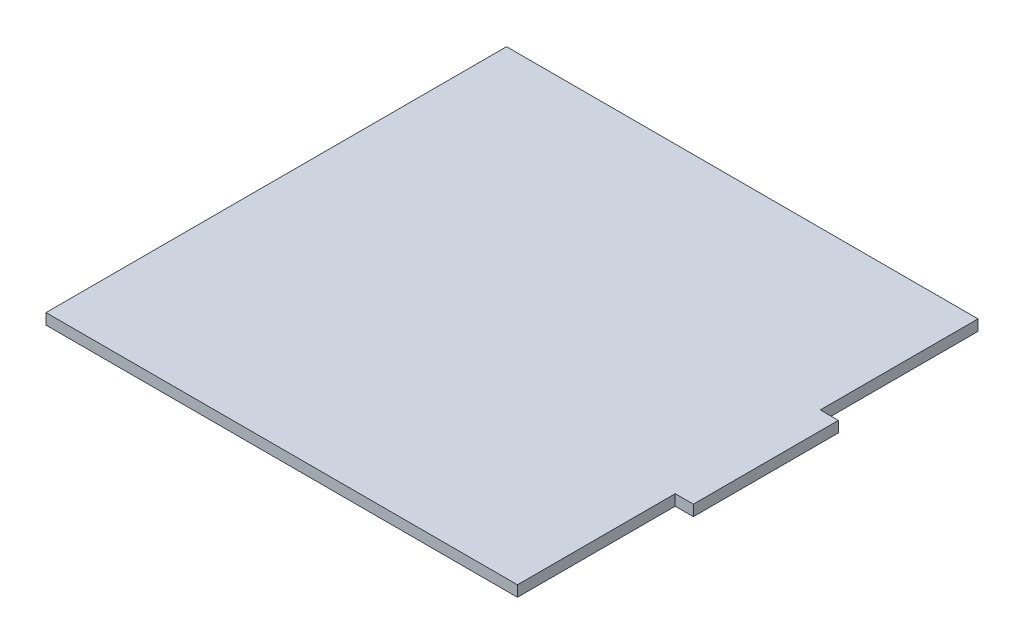
from build123d import *

# Parameters (mm, degrees)
BOSS_EXTRUDE1_DEPTH = 3


with BuildPart() as part:
    # Sketch1 → Boss-Extrude1 (new body)
    with BuildSketch(Plane(origin=(0, 0, 0), x_dir=(1, 0, 0), z_dir=(0, 1, 0))):
        Polygon((65, 20), (70, 20), (70, -20), (65, -20), (65, -63.5), (-65, -63.5), (-65, 63.5), (65, 63.5), align=None)
    extrude(amount=BOSS_EXTRUDE1_DEPTH)


solid = part.part
